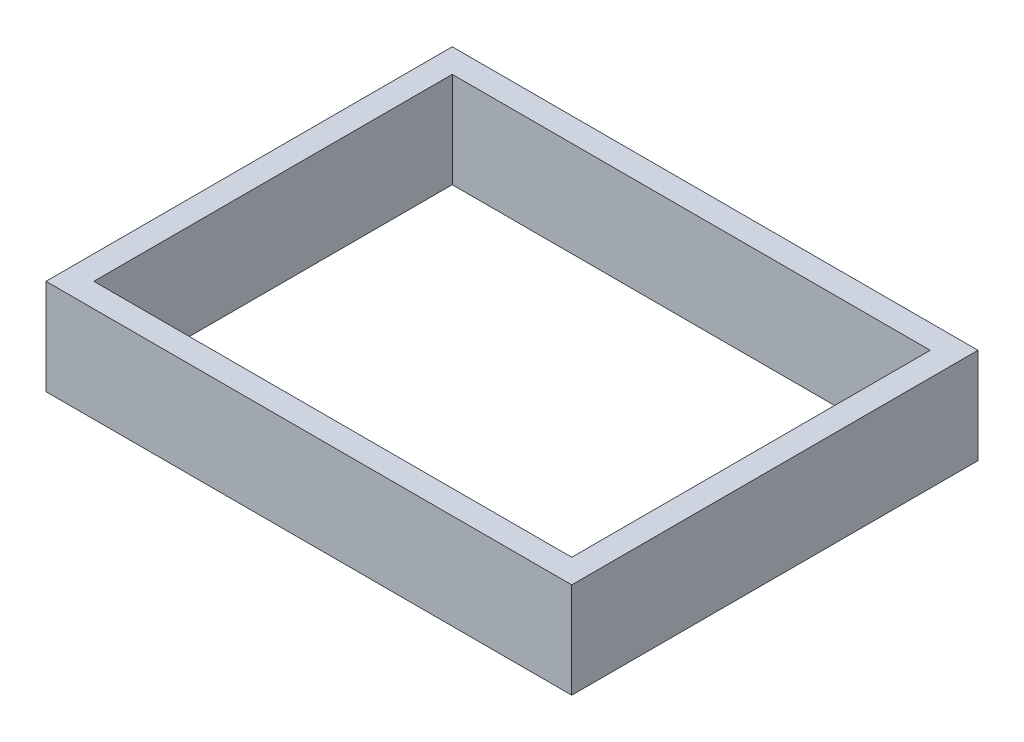
from build123d import *

# Parameters (mm, degrees)
SKETCH1_W           = 220
SKETCH1_H           = 170
SKETCH1_W_2         = 200
SKETCH1_H_2         = 150
BOSS_EXTRUDE1_DEPTH = 40


with BuildPart() as part:
    # Sketch1 → Boss-Extrude1 (new body)
    with BuildSketch(Plane(origin=(0, 0, 0), x_dir=(1, 0, 0), z_dir=(0, 1, 0))):
        with Locations((39.535727726, 16.923728896)):
            Rectangle(SKETCH1_W, SKETCH1_H)
        with Locations((39.535727726, 16.923728896)):
            Rectangle(SKETCH1_W_2, SKETCH1_H_2, mode=Mode.SUBTRACT)
    extrude(amount=BOSS_EXTRUDE1_DEPTH)


solid = part.part
